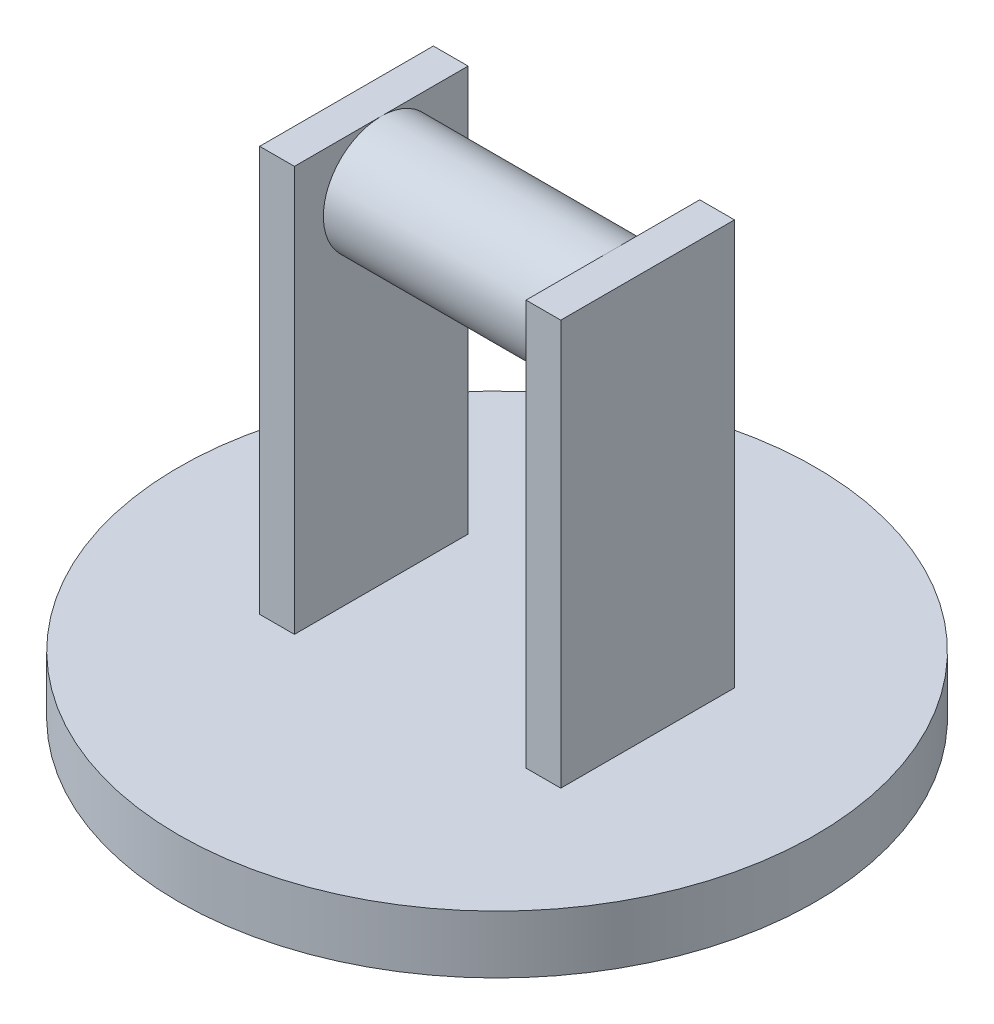
from build123d import *

# Parameters (mm, degrees)
SKETCH1_R           = 34.925
BOSS_EXTRUDE1_DEPTH = 6.35
SKETCH2_W           = 3.81
SKETCH2_H           = 19.05
BOSS_EXTRUDE2_DEPTH = 44.45
SKETCH3_R           = 6.35
BOSS_EXTRUDE3_DEPTH = 25.4


with BuildPart() as part:
    # Sketch1 → Boss-Extrude1 (new body)
    with BuildSketch(Plane(origin=(0, 0, 0), x_dir=(1, 0, 0), z_dir=(0, 1, 0))):
        Circle(SKETCH1_R)
    extrude(amount=BOSS_EXTRUDE1_DEPTH)

    # Sketch2 → Boss-Extrude2 (add)
    with BuildSketch(Plane(origin=(0, 6.35, 0), x_dir=(1, 0, 0), z_dir=(0, 1, 0))):
        with Locations((-14.605, 0)):
            Rectangle(SKETCH2_W, SKETCH2_H)
        with Locations((14.605, 0)):
            Rectangle(SKETCH2_W, SKETCH2_H)
    extrude(amount=BOSS_EXTRUDE2_DEPTH)

    # Sketch3 → Boss-Extrude3 (add)
    with BuildSketch(Plane(origin=(-12.7, 0, 0), x_dir=(0, 0, -1), z_dir=(1, 0, 0))):
        with Locations((0, 44.45)):
            Circle(SKETCH3_R)
    extrude(amount=BOSS_EXTRUDE3_DEPTH)


solid = part.part
